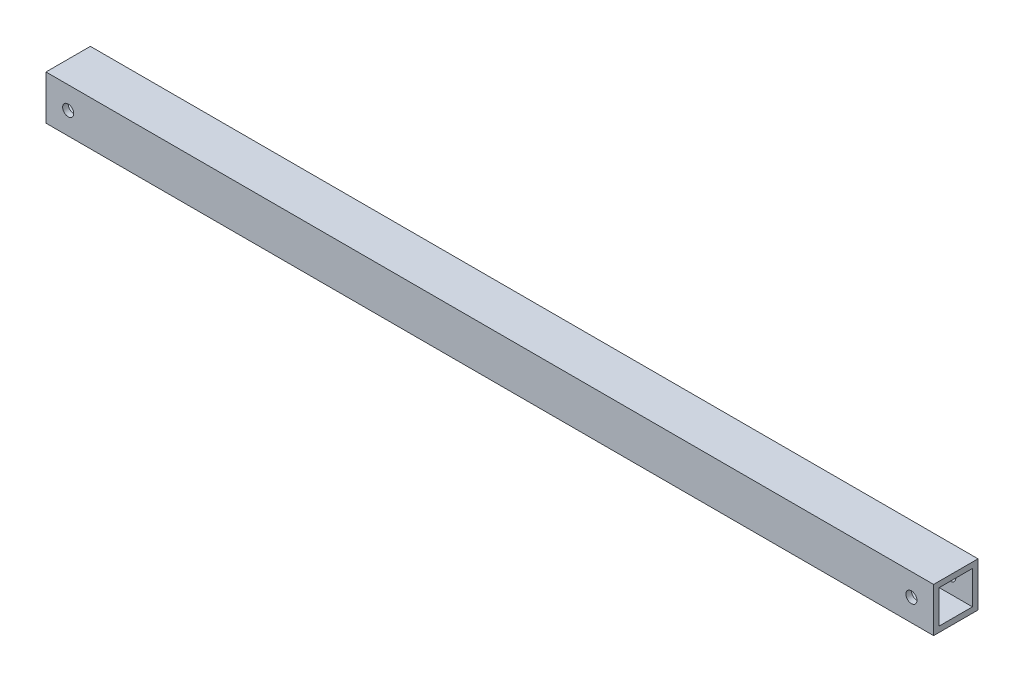
from build123d import *

# Parameters (mm, degrees)
SKETCH1_W           = 508
SKETCH1_H           = 25.4
BOSS_EXTRUDE1_DEPTH = 25.4
SKETCH2_W           = 9.525
SKETCH2_H           = 19.040717284
CUT_EXTRUDE1_DEPTH  = 508
SKETCH3_R           = 3.175
CUT_EXTRUDE2_DEPTH  = 508


with BuildPart() as part:
    # Sketch1 → Boss-Extrude1 (new body)
    with BuildSketch(Plane.XY):
        Rectangle(SKETCH1_W, SKETCH1_H)
    extrude(amount=BOSS_EXTRUDE1_DEPTH)

    # Sketch2 → Cut-Extrude1 (cut)
    with BuildSketch(Plane(origin=(254, 0, 0), x_dir=(0, 0, -1), z_dir=(1, 0, 0))):
        with Locations((-17.4625, 0)):
            Rectangle(SKETCH2_W, SKETCH2_H)
        with Locations((-7.9375, 0)):
            Rectangle(SKETCH2_W, SKETCH2_H)
    extrude(amount=-CUT_EXTRUDE1_DEPTH, mode=Mode.SUBTRACT)

    # Sketch3 → Cut-Extrude2 (cut)
    with BuildSketch(Plane.XY.offset(25.4)):
        with Locations((241.3, 0)):
            Circle(SKETCH3_R)
        with Locations((-241.3, 0)):
            Circle(SKETCH3_R)
    extrude(amount=-CUT_EXTRUDE2_DEPTH, mode=Mode.SUBTRACT)


solid = part.part
